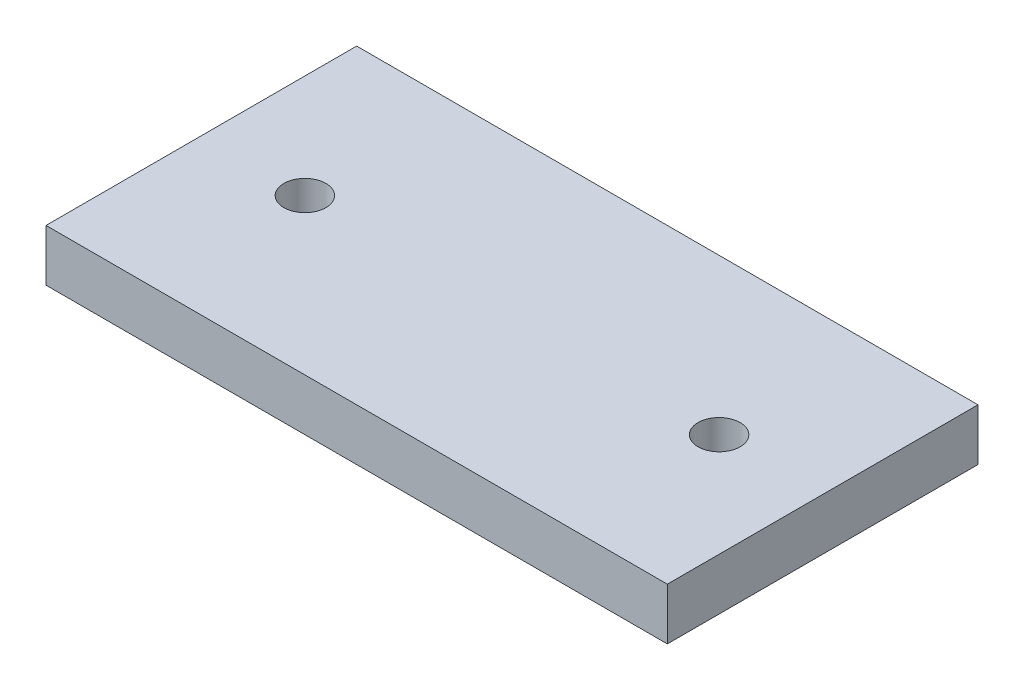
from build123d import *

# Parameters (mm, degrees)
SKETCH1_W           = 304.8
SKETCH1_H           = 152.4
SKETCH1_R           = 10.31875
BOSS_EXTRUDE1_DEPTH = 25.4


with BuildPart() as part:
    # Sketch1 → Boss-Extrude1 (new body)
    with BuildSketch(Plane(origin=(0, 0, 0), x_dir=(1, 0, 0), z_dir=(0, 1, 0))):
        with Locations((152.4, 76.2)):
            Rectangle(SKETCH1_W, SKETCH1_H)
        with Locations((50.8, 76.2)):
            Circle(SKETCH1_R, mode=Mode.SUBTRACT)
        with Locations((254, 76.2)):
            Circle(SKETCH1_R, mode=Mode.SUBTRACT)
    extrude(amount=BOSS_EXTRUDE1_DEPTH)


solid = part.part
